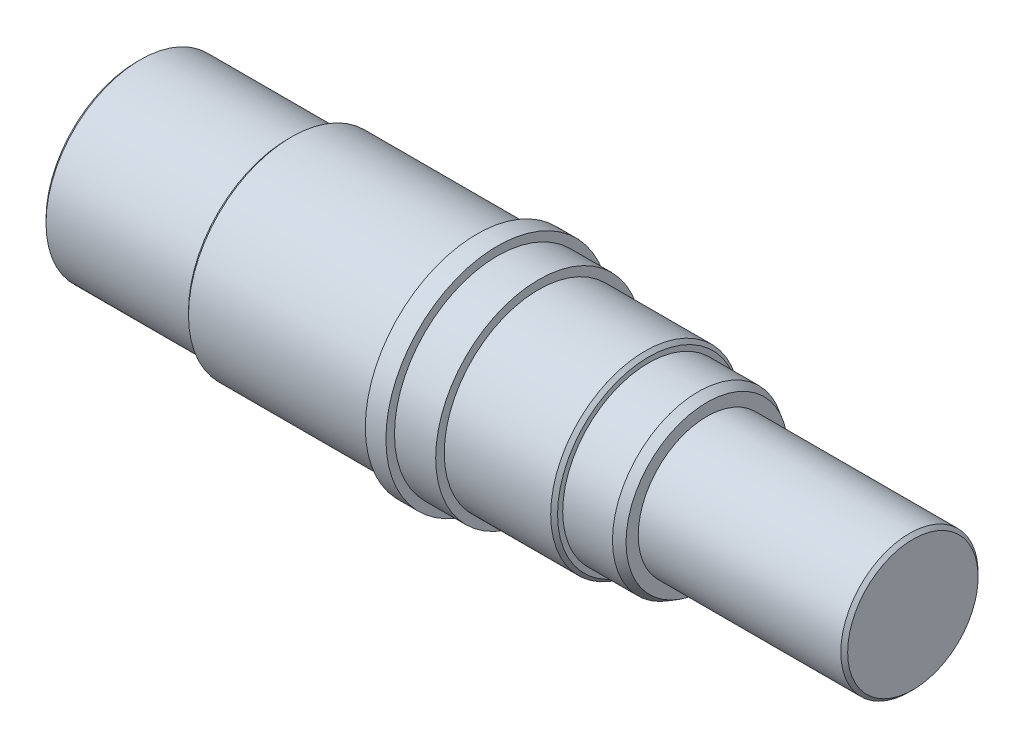
from build123d import *


with BuildPart() as part:
    # Skizze1 → Rotation1 (revolve)
    with BuildSketch(Plane.XY, mode=Mode.PRIVATE) as rotation1_sk:
        Polygon((168.152402442, 0), (168.152402442, 26.5), (169.152402442, 27.5), (184.152402442, 27.5), (212.152402442, 27.5), (212.152402442, 29), (213.152402442, 30), (267.152402442, 30), (267.152402442, 32.5), (273.152402442, 32.5), (273.152402442, 30), (285.152402442, 30), (285.152402442, 27.5), (297.652402442, 27.5), (316.152402442, 27.5), (317.152402442, 26.5), (317.152402442, 25), (331.652402442, 25), (334.152402442, 23.556624327), (334.152402442, 20), (393.152402442, 20), (394.152402442, 19), (394.152402442, 0), align=None)
    revolve(rotation1_sk.sketch.rotate(Axis((168.152402442, 0, 0), (1, 0, 0)), 90), axis=Axis((168.152402442, 0, 0), (1, 0, 0)))  # turned: the seam where the file's is


solid = part.part
